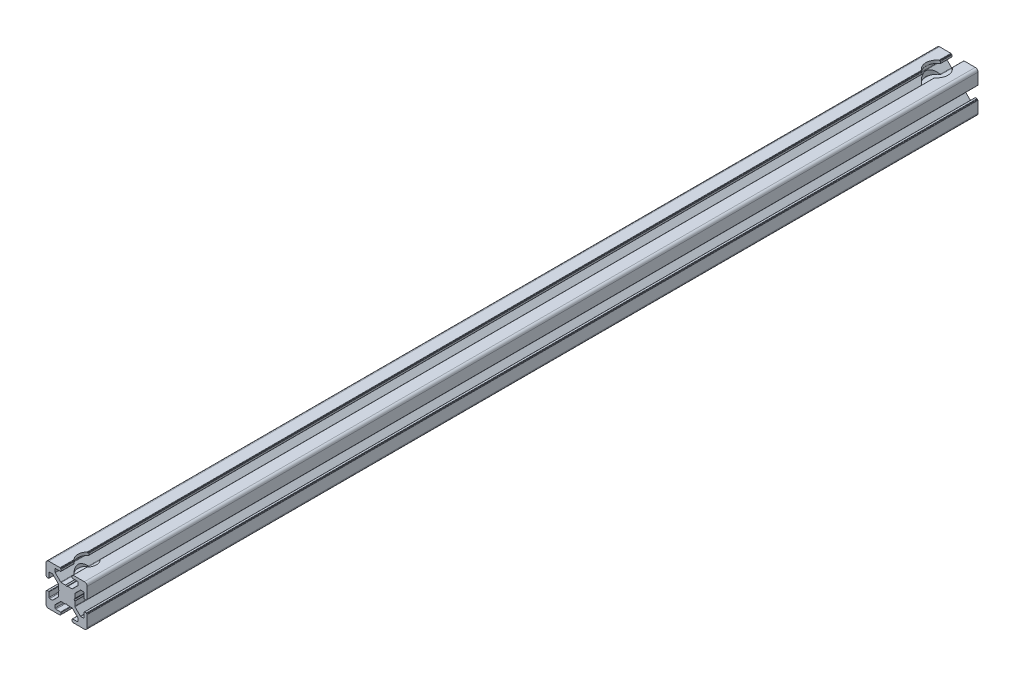
from build123d import *

# Parameters (mm, degrees)
BOSS_EXTRUDE1_DEPTH = 650
SKETCH2_R           = 4
CUT_EXTRUDE1_DEPTH  = 31
SKETCH3_R           = 8
SKETCH3_R_2         = 6.735835782
CUT_EXTRUDE2_DEPTH  = 9


with BuildPart() as part:
    # Sketch1 → Boss-Extrude1 (new body)
    with BuildSketch(Plane.XY):
        with BuildLine():
            Line((-12.8, 4.4), (-12.8, 7.85))
            ThreePointArc((-12.8, 7.85), (-12.653553391, 8.203553391), (-12.3, 8.35))
            Line((-12.3, 8.35), (-10.395584412, 8.35))
            ThreePointArc((-10.395584412, 8.35), (-10.204242696, 8.311939766), (-10.042031022, 8.203553391))
            Line((-10.042031022, 8.203553391), (-6.146446609, 4.307968978))
            ThreePointArc((-6.146446609, 4.307968978), (-6.038060234, 4.145757304), (-6, 3.954415588))
            Line((-6, 3.954415588), (-6, 0.933974596))
            ThreePointArc((-6, 0.933974596), (-5.982962913, 0.804565074), (-5.933012702, 0.683974596))
            Line((-5.933012702, 0.683974596), (-5.538119785, 0))
            Line((-5.538119785, 0), (-5.933012702, -0.683974596))
            ThreePointArc((-5.933012702, -0.683974596), (-5.982962913, -0.804565074), (-6, -0.933974596))
            Line((-6, -0.933974596), (-6, -3.954415588))
            ThreePointArc((-6, -3.954415588), (-6.038060234, -4.145757304), (-6.146446609, -4.307968978))
            Line((-6.146446609, -4.307968978), (-10.042031022, -8.203553391))
            ThreePointArc((-10.042031022, -8.203553391), (-10.204242696, -8.311939766), (-10.395584412, -8.35))
            Line((-10.395584412, -8.35), (-12.3, -8.35))
            ThreePointArc((-12.3, -8.35), (-12.653553391, -8.203553391), (-12.8, -7.85))
            Line((-12.8, -7.85), (-12.8, -4.4))
            ThreePointArc((-12.8, -4.4), (-12.887867966, -4.187867966), (-13.1, -4.1))
            Line((-13.1, -4.1), (-14.3, -4.1))
            ThreePointArc((-14.3, -4.1), (-14.441421356, -4.158578644), (-14.5, -4.3))
            Line((-14.5, -4.3), (-14.5, -4.4))
            ThreePointArc((-14.5, -4.4), (-14.558578644, -4.541421356), (-14.7, -4.6))
            Line((-14.7, -4.6), (-14.8, -4.6))
            ThreePointArc((-14.8, -4.6), (-14.941421356, -4.658578644), (-15, -4.8))
            Line((-15, -4.8), (-15, -13))
            ThreePointArc((-15, -13), (-14.414213562, -14.414213562), (-13, -15))
            Line((-13, -15), (-4.8, -15))
            ThreePointArc((-4.8, -15), (-4.658578644, -14.941421356), (-4.6, -14.8))
            Line((-4.6, -14.8), (-4.6, -14.7))
            ThreePointArc((-4.6, -14.7), (-4.541421356, -14.558578644), (-4.4, -14.5))
            Line((-4.4, -14.5), (-4.3, -14.5))
            ThreePointArc((-4.3, -14.5), (-4.158578644, -14.441421356), (-4.1, -14.3))
            Line((-4.1, -14.3), (-4.1, -13.1))
            ThreePointArc((-4.1, -13.1), (-4.187867966, -12.887867966), (-4.4, -12.8))
            Line((-4.4, -12.8), (-7.85, -12.8))
            ThreePointArc((-7.85, -12.8), (-8.203553391, -12.653553391), (-8.35, -12.3))
            Line((-8.35, -12.3), (-8.35, -10.395584412))
            ThreePointArc((-8.35, -10.395584412), (-8.311939766, -10.204242696), (-8.203553391, -10.042031022))
            Line((-8.203553391, -10.042031022), (-4.307968978, -6.146446609))
            ThreePointArc((-4.307968978, -6.146446609), (-4.145757304, -6.038060234), (-3.954415588, -6))
            Line((-3.954415588, -6), (-0.933974596, -6))
            ThreePointArc((-0.933974596, -6), (-0.804565074, -5.982962913), (-0.683974596, -5.933012702))
            Line((-0.683974596, -5.933012702), (0, -5.538119785))
            Line((0, -5.538119785), (0.683974596, -5.933012702))
            ThreePointArc((0.683974596, -5.933012702), (0.804565074, -5.982962913), (0.933974596, -6))
            Line((0.933974596, -6), (3.954415588, -6))
            ThreePointArc((3.954415588, -6), (4.145757304, -6.038060234), (4.307968978, -6.146446609))
            Line((4.307968978, -6.146446609), (8.203553391, -10.042031022))
            ThreePointArc((8.203553391, -10.042031022), (8.311939766, -10.204242696), (8.35, -10.395584412))
            Line((8.35, -10.395584412), (8.35, -12.3))
            ThreePointArc((8.35, -12.3), (8.203553391, -12.653553391), (7.85, -12.8))
            Line((7.85, -12.8), (4.4, -12.8))
            ThreePointArc((4.4, -12.8), (4.187867966, -12.887867966), (4.1, -13.1))
            Line((4.1, -13.1), (4.1, -14.3))
            ThreePointArc((4.1, -14.3), (4.158578644, -14.441421356), (4.3, -14.5))
            Line((4.3, -14.5), (4.4, -14.5))
            ThreePointArc((4.4, -14.5), (4.541421356, -14.558578644), (4.6, -14.7))
            Line((4.6, -14.7), (4.6, -14.8))
            ThreePointArc((4.6, -14.8), (4.658578644, -14.941421356), (4.8, -15))
            Line((4.8, -15), (13, -15))
            ThreePointArc((13, -15), (14.414213562, -14.414213562), (15, -13))
            Line((15, -13), (15, -4.8))
            ThreePointArc((15, -4.8), (14.941421356, -4.658578644), (14.8, -4.6))
            Line((14.8, -4.6), (14.7, -4.6))
            ThreePointArc((14.7, -4.6), (14.558578644, -4.541421356), (14.5, -4.4))
            Line((14.5, -4.4), (14.5, -4.3))
            ThreePointArc((14.5, -4.3), (14.441421356, -4.158578644), (14.3, -4.1))
            Line((14.3, -4.1), (13.1, -4.1))
            ThreePointArc((13.1, -4.1), (12.887867966, -4.187867966), (12.8, -4.4))
            Line((12.8, -4.4), (12.8, -7.85))
            ThreePointArc((12.8, -7.85), (12.653553391, -8.203553391), (12.3, -8.35))
            Line((12.3, -8.35), (10.395584412, -8.35))
            ThreePointArc((10.395584412, -8.35), (10.204242696, -8.311939766), (10.042031022, -8.203553391))
            Line((10.042031022, -8.203553391), (6.146446609, -4.307968978))
            ThreePointArc((6.146446609, -4.307968978), (6.038060234, -4.145757304), (6, -3.954415588))
            Line((6, -3.954415588), (6, -0.933974596))
            ThreePointArc((6, -0.933974596), (5.982962913, -0.804565074), (5.933012702, -0.683974596))
            Line((5.933012702, -0.683974596), (5.538119785, 0))
            Line((5.538119785, 0), (5.933012702, 0.683974596))
            ThreePointArc((5.933012702, 0.683974596), (5.982962913, 0.804565074), (6, 0.933974596))
            Line((6, 0.933974596), (6, 3.954415588))
            ThreePointArc((6, 3.954415588), (6.038060234, 4.145757304), (6.146446609, 4.307968978))
            Line((6.146446609, 4.307968978), (10.042031022, 8.203553391))
            ThreePointArc((10.042031022, 8.203553391), (10.204242696, 8.311939766), (10.395584412, 8.35))
            Line((10.395584412, 8.35), (12.3, 8.35))
            ThreePointArc((12.3, 8.35), (12.653553391, 8.203553391), (12.8, 7.85))
            Line((12.8, 7.85), (12.8, 4.4))
            ThreePointArc((12.8, 4.4), (12.887867966, 4.187867966), (13.1, 4.1))
            Line((13.1, 4.1), (14.3, 4.1))
            ThreePointArc((14.3, 4.1), (14.441421356, 4.158578644), (14.5, 4.3))
            Line((14.5, 4.3), (14.5, 4.4))
            ThreePointArc((14.5, 4.4), (14.558578644, 4.541421356), (14.7, 4.6))
            Line((14.7, 4.6), (14.8, 4.6))
            ThreePointArc((14.8, 4.6), (14.941421356, 4.658578644), (15, 4.8))
            Line((15, 4.8), (15, 13))
            ThreePointArc((15, 13), (14.414213562, 14.414213562), (13, 15))
            Line((13, 15), (4.8, 15))
            ThreePointArc((4.8, 15), (4.658578644, 14.941421356), (4.6, 14.8))
            Line((4.6, 14.8), (4.6, 14.7))
            ThreePointArc((4.6, 14.7), (4.541421356, 14.558578644), (4.4, 14.5))
            Line((4.4, 14.5), (4.3, 14.5))
            ThreePointArc((4.3, 14.5), (4.158578644, 14.441421356), (4.1, 14.3))
            Line((4.1, 14.3), (4.1, 13.1))
            ThreePointArc((4.1, 13.1), (4.187867966, 12.887867966), (4.4, 12.8))
            Line((4.4, 12.8), (7.85, 12.8))
            ThreePointArc((7.85, 12.8), (8.203553391, 12.653553391), (8.35, 12.3))
            Line((8.35, 12.3), (8.35, 10.395584412))
            ThreePointArc((8.35, 10.395584412), (8.311939766, 10.204242696), (8.203553391, 10.042031022))
            Line((8.203553391, 10.042031022), (4.307968978, 6.146446609))
            ThreePointArc((4.307968978, 6.146446609), (4.145757304, 6.038060234), (3.954415588, 6))
            Line((3.954415588, 6), (0.933974596, 6))
            ThreePointArc((0.933974596, 6), (0.804565074, 5.982962913), (0.683974596, 5.933012702))
            Line((0.683974596, 5.933012702), (0, 5.538119785))
            Line((0, 5.538119785), (-0.683974596, 5.933012702))
            ThreePointArc((-0.683974596, 5.933012702), (-0.804565074, 5.982962913), (-0.933974596, 6))
            Line((-0.933974596, 6), (-3.954415588, 6))
            ThreePointArc((-3.954415588, 6), (-4.145757304, 6.038060234), (-4.307968978, 6.146446609))
            Line((-4.307968978, 6.146446609), (-8.203553391, 10.042031022))
            ThreePointArc((-8.203553391, 10.042031022), (-8.311939766, 10.204242696), (-8.35, 10.395584412))
            Line((-8.35, 10.395584412), (-8.35, 12.3))
            ThreePointArc((-8.35, 12.3), (-8.203553391, 12.653553391), (-7.85, 12.8))
            Line((-7.85, 12.8), (-4.4, 12.8))
            ThreePointArc((-4.4, 12.8), (-4.187867966, 12.887867966), (-4.1, 13.1))
            Line((-4.1, 13.1), (-4.1, 14.3))
            ThreePointArc((-4.1, 14.3), (-4.158578644, 14.441421356), (-4.3, 14.5))
            Line((-4.3, 14.5), (-4.4, 14.5))
            ThreePointArc((-4.4, 14.5), (-4.541421356, 14.558578644), (-4.6, 14.7))
            Line((-4.6, 14.7), (-4.6, 14.8))
            ThreePointArc((-4.6, 14.8), (-4.658578644, 14.941421356), (-4.8, 15))
            Line((-4.8, 15), (-13, 15))
            ThreePointArc((-13, 15), (-14.414213562, 14.414213562), (-15, 13))
            Line((-15, 13), (-15, 4.8))
            ThreePointArc((-15, 4.8), (-14.941421356, 4.658578644), (-14.8, 4.6))
            Line((-14.8, 4.6), (-14.7, 4.6))
            ThreePointArc((-14.7, 4.6), (-14.558578644, 4.541421356), (-14.5, 4.4))
            Line((-14.5, 4.4), (-14.5, 4.3))
            ThreePointArc((-14.5, 4.3), (-14.441421356, 4.158578644), (-14.3, 4.1))
            Line((-14.3, 4.1), (-13.1, 4.1))
            ThreePointArc((-13.1, 4.1), (-12.887867966, 4.187867966), (-12.8, 4.4))
        make_face()
    extrude(amount=BOSS_EXTRUDE1_DEPTH)

    # Sketch2 → Cut-Extrude1 (cut, through all)
    with BuildSketch(Plane(origin=(0, 15, 0), x_dir=(1, 0, 0), z_dir=(0, 1, 0))):
        with Locations((0, -15)):
            Circle(SKETCH2_R)
        with Locations((0, -635)):
            Circle(SKETCH2_R)
    extrude(amount=-CUT_EXTRUDE1_DEPTH, mode=Mode.SUBTRACT)

    # Sketch3 → Cut-Extrude2 (cut)
    with BuildSketch(Plane(origin=(0, 15, 0), x_dir=(1, 0, 0), z_dir=(0, 1, 0))):
        with Locations((0, -15)):
            Circle(SKETCH3_R)
        with Locations((0, -635)):
            Circle(SKETCH3_R_2)
    extrude(amount=-CUT_EXTRUDE2_DEPTH, mode=Mode.SUBTRACT)


solid = part.part
